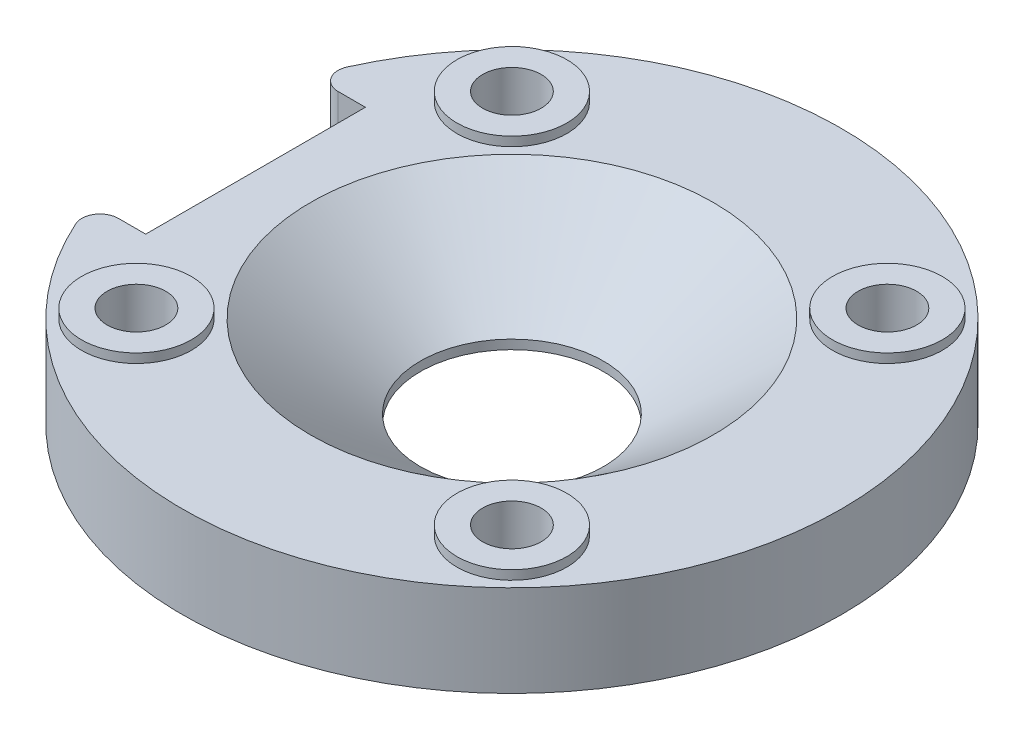
from build123d import *

# Parameters (mm, degrees)
SKETCH1_R            = 18
SKETCH1_R_2          = 5
BODY_DEPTH           = 5
OBJECTIVE_RING_SIZE  = 6
OBJECTIVE_RING_SIZE2 = 4.5
BOLTS_DEPTH          = 10
BOLTS_DEPTH_BACK     = 10
SKETCH6_R            = 1.6
WASH_START           = 0.5
SKETCH8_R            = 3
SKETCH8_R_2          = 1.6
WASH_DEPTH           = 0.5
SPE_DEPTH            = 10
SPE_DEPTH_BACK       = 9.5
SKETCH9_W            = 8
SKETCH9_H            = 12
SPE_FILLET_R         = 1


with BuildPart() as part:
    # Sketch1 → Body (new body)
    with BuildSketch(Plane(origin=(0, 0, 0), x_dir=(1, 0, 0), z_dir=(0, 1, 0))):
        Circle(SKETCH1_R)
        Circle(SKETCH1_R_2, mode=Mode.SUBTRACT)
    extrude(amount=BODY_DEPTH)

    # Objective_ring
    objective_ring_edges = [part.edges().sort_by_distance(p)[0] for p in [
        (-5, 5, 0),
    ]]
    objective_ring_side = [part.faces().sort_by_distance(p)[0] for p in [
        (-17.490883118, 5, 0),
    ]]
    chamfer(objective_ring_edges, length=OBJECTIVE_RING_SIZE, length2=OBJECTIVE_RING_SIZE2, reference=objective_ring_side[0])

    # Sketch6 → Bolts (cut, two sides: drawn at the far end of the back side and taken through both)
    with BuildSketch(Plane(origin=(0, 5, 0), x_dir=(1, 0, 0), z_dir=(0, 1, 0)).offset(-BOLTS_DEPTH_BACK)):
        with Locations((-10.253048327, 10.253048327)):
            Circle(SKETCH6_R)
        with Locations((-10.253048327, -10.253048327)):
            Circle(SKETCH6_R)
        with Locations((10.253048327, -10.253048327)):
            Circle(SKETCH6_R)
        with Locations((10.253048327, 10.253048327)):
            Circle(SKETCH6_R)
    extrude(amount=BOLTS_DEPTH + BOLTS_DEPTH_BACK, mode=Mode.SUBTRACT)

    # Sketch8 → Wash (add)
    # profile 1 of 4: a face of its own
    with BuildSketch(Plane(origin=(0, 5, 0), x_dir=(1, 0, 0), z_dir=(0, 1, 0)).offset(WASH_START)):
        with Locations((-10.253048327, 10.253048327)):
            Circle(SKETCH8_R)
        with Locations((-10.253048327, 10.253048327)):
            Circle(SKETCH8_R_2, mode=Mode.SUBTRACT)
    # profile 2 of 4: a face of its own
    with BuildSketch(Plane(origin=(0, 5, 0), x_dir=(1, 0, 0), z_dir=(0, 1, 0)).offset(WASH_START)):
        with Locations((10.253048327, 10.253048327)):
            Circle(SKETCH8_R)
        with Locations((10.253048327, 10.253048327)):
            Circle(SKETCH8_R_2, mode=Mode.SUBTRACT)
    # profile 3 of 4: a face of its own
    with BuildSketch(Plane(origin=(0, 5, 0), x_dir=(1, 0, 0), z_dir=(0, 1, 0)).offset(WASH_START)):
        with Locations((10.253048327, -10.253048327)):
            Circle(SKETCH8_R)
        with Locations((10.253048327, -10.253048327)):
            Circle(SKETCH8_R_2, mode=Mode.SUBTRACT)
    # profile 4 of 4: a face of its own
    with BuildSketch(Plane(origin=(0, 5, 0), x_dir=(1, 0, 0), z_dir=(0, 1, 0)).offset(WASH_START)):
        with Locations((-10.253048327, -10.253048327)):
            Circle(SKETCH8_R)
        with Locations((-10.253048327, -10.253048327)):
            Circle(SKETCH8_R_2, mode=Mode.SUBTRACT)
    extrude(amount=-WASH_DEPTH)

    # Sketch9 → SPE (cut, two sides: drawn at the far end of the back side and taken through both)
    with BuildSketch(Plane(origin=(0, 5, 0), x_dir=(1, 0, 0), z_dir=(0, 1, 0)).offset(-SPE_DEPTH_BACK)):
        with Locations((-18, 0)):
            Rectangle(SKETCH9_W, SKETCH9_H)
    extrude(amount=SPE_DEPTH + SPE_DEPTH_BACK, mode=Mode.SUBTRACT)

    # SPE_Fillet
    spe_fillet_edges = [part.edges().sort_by_distance(p)[0] for p in [
        (-16.970562748, 2.5, 6),
        (-16.970562748, 2.5, -6),
    ]]
    fillet(spe_fillet_edges, radius=SPE_FILLET_R)


solid = part.part
